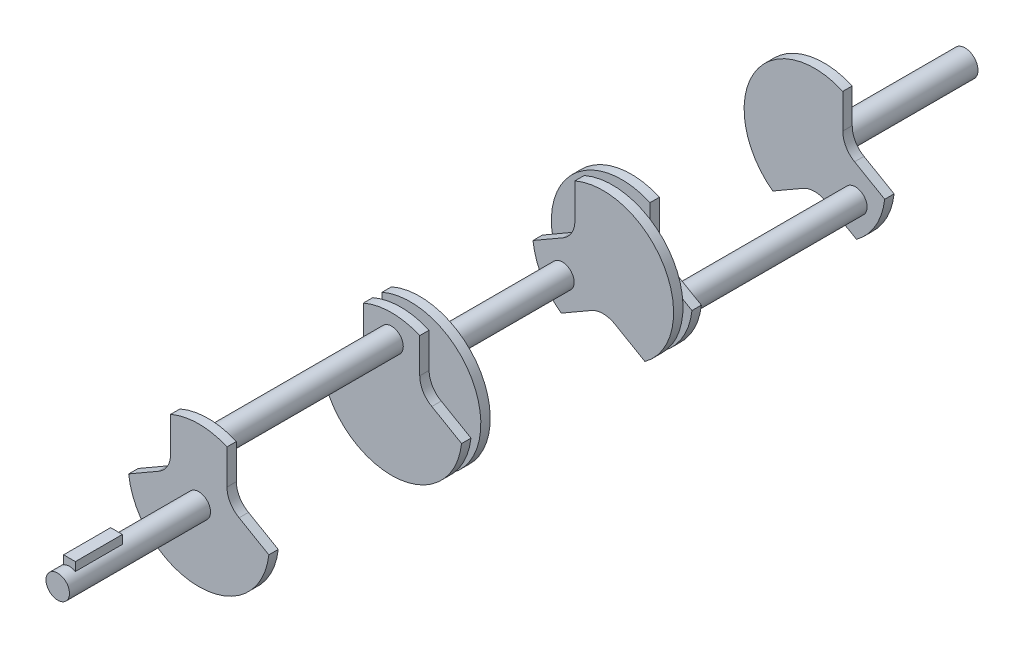
from build123d import *

# Parameters (mm, degrees)
BOSS_EXTRUDE1_DEPTH   = 5.08
LPATTERN1_COUNT       = 2
LPATTERN1_PITCH       = 104.14
SKETCH2_R             = 6.35
BOSS_EXTRUDE2_DEPTH   = 104.14
LPATTERN2_COUNT       = 3
LPATTERN2_PITCH       = 114.3
BODY_MOVE_COPY1_ANGLE = 120
BODY_MOVE_COPY2_ANGLE = 120
SKETCH3_R             = 12.7
BOSS_EXTRUDE3_DEPTH   = 5.08
BOSS_EXTRUDE4_START   = 114.3
SKETCH3_2_R           = 12.7
BOSS_EXTRUDE4_DEPTH   = 5.08
SKETCH4_R             = 6.985
BOSS_EXTRUDE5_DEPTH   = 76.2
SKETCH5_R             = 6.35
BOSS_EXTRUDE6_DEPTH   = 76.2
BOSS_EXTRUDE8_START   = 5.499261
SKETCH6_W             = 6.35
SKETCH6_H             = 25.4
BOSS_EXTRUDE8_DEPTH   = 4.660739


with BuildPart() as part:
    # Sketch1 → Boss-Extrude1 (new body)
    with BuildSketch(Plane.XY):
        with BuildLine():
            ThreePointArc((21.401887456, 5.241250721), (16.887307357, 9.873763366), (15.24, 16.129))
            Line((15.24, 16.129), (15.24, 34.919226796))
            ThreePointArc((15.24, 34.919226796), (0, 38.1), (-15.24, 34.919226796))
            Line((-15.24, 34.919226796), (-15.24, 16.129))
            ThreePointArc((-15.24, 16.129), (-16.887307357, 9.873763366), (-21.401887456, 5.241250721))
            ThreePointArc((-21.401887456, 5.241250721), (-21.59, 5.130477372), (-21.779988806, 5.022953805))
            Line((-21.779988806, 5.022953805), (-37.860937485, -4.261386244))
            ThreePointArc((-37.860937485, -4.261386244), (0, -38.1), (37.860937485, -4.261386244))
            Line((37.860937485, -4.261386244), (21.779988806, 5.022953805))
            ThreePointArc((21.779988806, 5.022953805), (21.59, 5.130477372), (21.401887456, 5.241250721))
        make_face()
    extrude(amount=-BOSS_EXTRUDE1_DEPTH)


with BuildPart() as lpattern1_1:
    # LPattern1: pattern copy
    add(part.part.moved(Location(Vector(0, 0, -1) * (1 * LPATTERN1_PITCH))))


with BuildPart() as part_1:
    add(part.part)

    add(lpattern1_1.part)  # Boss-Extrude2 merges LPattern1_1
    # Sketch2 → Boss-Extrude2 (add)
    with BuildSketch(Plane(origin=(0, 0, -5.08), x_dir=(-1, 0, 0), z_dir=(0, 0, -1))):
        with Locations((0, 25.4)):
            Circle(SKETCH2_R)
    extrude(amount=BOSS_EXTRUDE2_DEPTH)


with BuildPart() as lpattern2_1:
    # LPattern2: pattern copy
    add(part_1.part.moved(Location(Vector(0, 0, -1) * (1 * LPATTERN2_PITCH))))


with BuildPart() as lpattern2_2:
    # LPattern2: pattern copy
    add(part_1.part.moved(Location(Vector(0, 0, -1) * (2 * LPATTERN2_PITCH))))


with BuildPart() as lpattern2_1_1:
    # Body-Move_Copy1: moved
    add(lpattern2_1.part.rotate(Axis((0, 0, 0), (0, 0, 1)), BODY_MOVE_COPY1_ANGLE))


with BuildPart() as lpattern2_2_1:
    # Body-Move_Copy2: moved
    add(lpattern2_2.part.rotate(Axis((0, 0, 0), (0, 0, -1)), BODY_MOVE_COPY2_ANGLE))


with BuildPart() as part_2:
    add(part_1.part)

    add(lpattern2_1_1.part)  # Boss-Extrude3 merges LPattern2_1
    # Sketch3 → Boss-Extrude3 (add)
    with BuildSketch(Plane(origin=(0, 0, -109.22), x_dir=(-1, 0, 0), z_dir=(0, 0, -1))):
        Circle(SKETCH3_R)
    extrude(amount=BOSS_EXTRUDE3_DEPTH)

    add(lpattern2_2_1.part)  # Boss-Extrude4 merges LPattern2_2
    # Sketch3_2 → Boss-Extrude4 (add)
    with BuildSketch(Plane(origin=(0, 0, -109.22), x_dir=(-1, 0, 0), z_dir=(0, 0, -1)).offset(BOSS_EXTRUDE4_START)):
        Circle(SKETCH3_2_R)
    extrude(amount=BOSS_EXTRUDE4_DEPTH)

    # Sketch4 → Boss-Extrude5 (add)
    with BuildSketch(Plane(origin=(0, 0, -337.82), x_dir=(-1, 0, 0), z_dir=(0, 0, -1))):
        Circle(SKETCH4_R)
    extrude(amount=BOSS_EXTRUDE5_DEPTH)

    # Sketch5 → Boss-Extrude6 (add)
    with BuildSketch(Plane.XY):
        Circle(SKETCH5_R)
    extrude(amount=BOSS_EXTRUDE6_DEPTH)

    # Sketch6 → Boss-Extrude8 (add)
    with BuildSketch(Plane(origin=(0, 0, 0), x_dir=(1, 0, 0), z_dir=(0, 1, 0)).offset(BOSS_EXTRUDE8_START)):
        with Locations((0, -57.15)):
            Rectangle(SKETCH6_W, SKETCH6_H)
    extrude(amount=BOSS_EXTRUDE8_DEPTH)


solid = part_2.part
